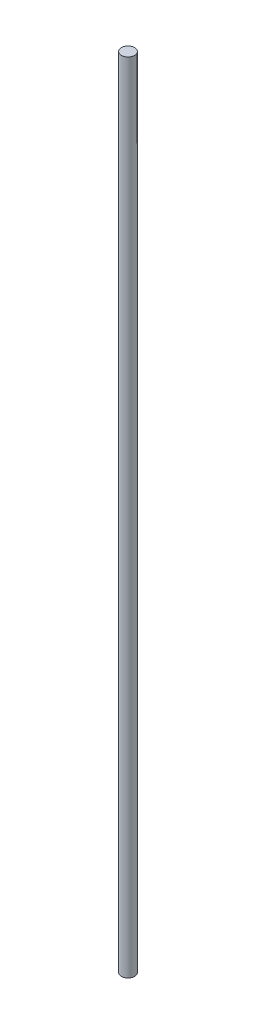
from build123d import *

# Parameters (mm, degrees)
SKETCH1_R           = 4
BOSS_EXTRUDE1_DEPTH = 475


with BuildPart() as part:
    # Sketch1 → Boss-Extrude1 (new body)
    with BuildSketch(Plane(origin=(0, 0, 0), x_dir=(1, 0, 0), z_dir=(0, 1, 0))):
        Circle(SKETCH1_R)
    extrude(amount=BOSS_EXTRUDE1_DEPTH)


solid = part.part
